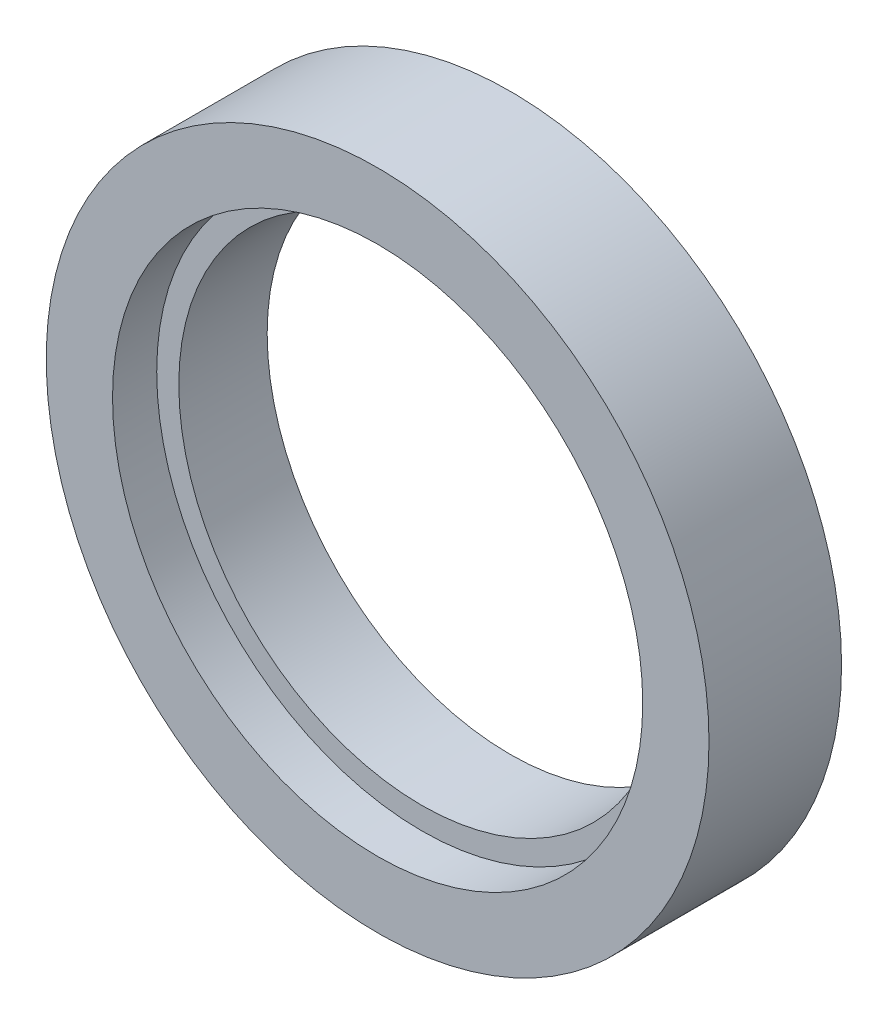
from build123d import *

# Parameters (mm, degrees)
ESQUISSE1_R             = 7.5
ESQUISSE1_R_2           = 5.5
BOSS_EXTRU_1_DEPTH      = 3
ESQUISSE2_R             = 6
ENL_V_MAT_EXTRU_1_DEPTH = 1


with BuildPart() as part:
    # Esquisse1 → Boss.-Extru.1 (new body)
    with BuildSketch(Plane.XY):
        Circle(ESQUISSE1_R)
        Circle(ESQUISSE1_R_2, mode=Mode.SUBTRACT)
    extrude(amount=BOSS_EXTRU_1_DEPTH)

    # Esquisse2 → Enlèv. mat.-Extru.1 (cut)
    with BuildSketch(Plane.XY.offset(3)):
        Circle(ESQUISSE2_R)
    extrude(amount=-ENL_V_MAT_EXTRU_1_DEPTH, mode=Mode.SUBTRACT)


solid = part.part
